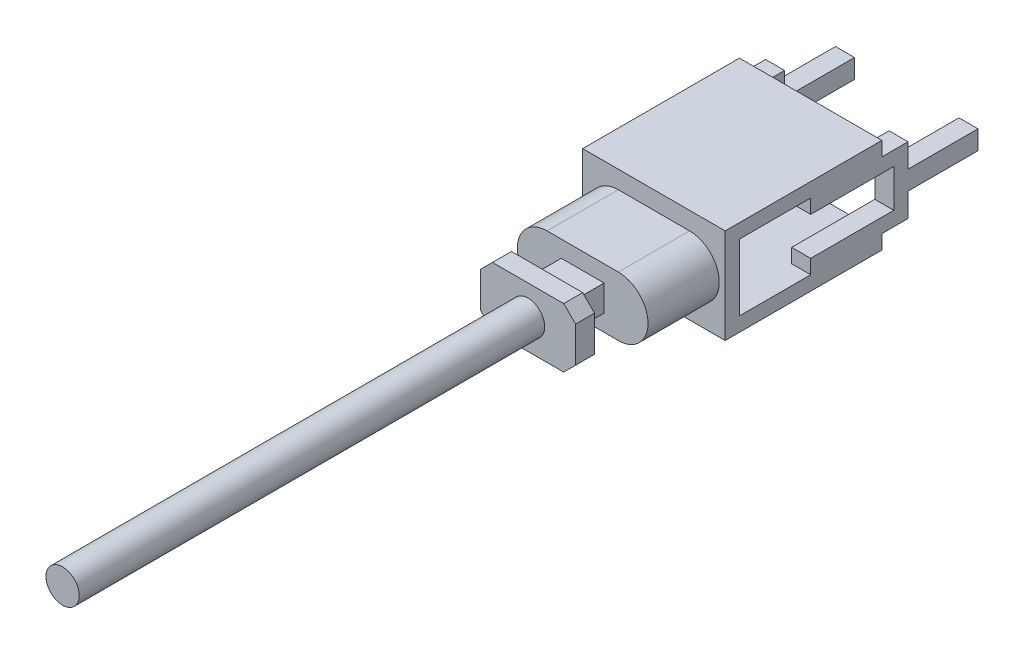
from build123d import *

# Parameters (mm, degrees)
SKETCH_1_R             = 7
EXTRUDE_1_DEPTH        = 160
EXTRUDE_1_DEPTH_BACK   = 36
SKETCH_2_R             = 7
EXTRUDE_2_DEPTH        = 8
SKETCH_3_W             = 18
SKETCH_3_H             = 11
EXTRUDE_3_DEPTH        = 15
EXTRUDE_4_DEPTH        = 30
SKETCH_5_W             = 60
SKETCH_5_H             = 40
EXTRUDE_5_DEPTH        = 6
SKETCH_6_W             = 60
SKETCH_6_H             = 6
EXTRUDE_6_DEPTH        = 60
SKETCH_7_W             = 29.455878384
SKETCH_7_H             = 4
EXTRUDE_7_DEPTH        = 8
PATTERN_LINEAR_1_COUNT = 2
PATTERN_LINEAR_1_PITCH = 52


with BuildPart() as part:
    # 草图1 → 凸台-拉伸1 (new body, two sides)
    with BuildSketch(Plane.XY) as extrude_1_sk:
        Circle(SKETCH_1_R)
    extrude(amount=EXTRUDE_1_DEPTH)
    extrude(extrude_1_sk.sketch, amount=-EXTRUDE_1_DEPTH_BACK)

    # 草图2 → 凸台-拉伸2 (add)
    with BuildSketch(Plane(origin=(0, 0, -36), x_dir=(-1, 0, 0), z_dir=(0, 0, -1))):
        Polygon((20, 7.5), (15, 12.5), (-15, 12.5), (-20, 7.5), (-20, -7.5), (-15, -12.5), (15, -12.5), (20, -7.5), align=None)
        Circle(SKETCH_2_R, mode=Mode.SUBTRACT)
        Circle(SKETCH_2_R)
    extrude(amount=EXTRUDE_2_DEPTH)

    # 草图3 → 凸台-拉伸3 (add)
    with BuildSketch(Plane(origin=(0, 0, -44), x_dir=(-1, 0, 0), z_dir=(0, 0, -1))):
        Rectangle(SKETCH_3_W, SKETCH_3_H)
    extrude(amount=EXTRUDE_3_DEPTH)

    # 草图4 → 凸台-拉伸4 (add)
    with BuildSketch(Plane(origin=(0, 0, -59), x_dir=(-1, 0, 0), z_dir=(0, 0, -1))):
        with BuildLine():
            Line((-15, -12.5), (-15, 12.5))
            ThreePointArc((-15, 12.5), (-27.5, 0), (-15, -12.5))
        make_face()
        with BuildLine():
            ThreePointArc((-3.77502784, 5.5), (-8.385621722, 10.606601718), (-15, 12.5))
            Line((-15, 12.5), (-15, -12.5))
            ThreePointArc((-15, -12.5), (-8.385621722, -10.606601718), (-3.77502784, -5.5))
            Line((-3.77502784, -5.5), (-9, -5.5))
            Line((-9, -5.5), (-9, 5.5))
            Line((-9, 5.5), (-3.77502784, 5.5))
        make_face()
        with BuildLine():
            ThreePointArc((-2.5, 0), (-2.822928267, 2.822928267), (-3.77502784, 5.5))
            Line((-3.77502784, 5.5), (-9, 5.5))
            Line((-9, 5.5), (-9, -5.5))
            Line((-9, -5.5), (-3.77502784, -5.5))
            ThreePointArc((-3.77502784, -5.5), (-2.822928267, -2.822928267), (-2.5, 0))
        make_face()
        with BuildLine():
            ThreePointArc((3.77502784, -5.5), (2.5, 0), (3.77502784, 5.5))
            Line((3.77502784, 5.5), (-3.77502784, 5.5))
            ThreePointArc((-3.77502784, 5.5), (-2.822928267, 2.822928267), (-2.5, 0))
            ThreePointArc((-2.5, 0), (-2.822928267, -2.822928267), (-3.77502784, -5.5))
            Line((-3.77502784, -5.5), (3.77502784, -5.5))
        make_face()
        with BuildLine():
            Line((9, 5.5), (3.77502784, 5.5))
            ThreePointArc((3.77502784, 5.5), (2.5, 0), (3.77502784, -5.5))
            Line((3.77502784, -5.5), (9, -5.5))
            Line((9, -5.5), (9, 5.5))
        make_face()
        with BuildLine():
            Line((15, -12.5), (15, 12.5))
            ThreePointArc((15, 12.5), (8.385621722, 10.606601718), (3.77502784, 5.5))
            Line((3.77502784, 5.5), (9, 5.5))
            Line((9, 5.5), (9, -5.5))
            Line((9, -5.5), (3.77502784, -5.5))
            ThreePointArc((3.77502784, -5.5), (8.385621722, -10.606601718), (15, -12.5))
        make_face()
        with BuildLine():
            ThreePointArc((27.5, 0), (23.838834765, 8.838834765), (15, 12.5))
            Line((15, 12.5), (15, -12.5))
            ThreePointArc((15, -12.5), (23.838834765, -8.838834765), (27.5, 0))
        make_face()
        with BuildLine():
            Line((-15, -12.5), (15, -12.5))
            ThreePointArc((15, -12.5), (8.385621722, -10.606601718), (3.77502784, -5.5))
            Line((3.77502784, -5.5), (-3.77502784, -5.5))
            ThreePointArc((-3.77502784, -5.5), (-8.385621722, -10.606601718), (-15, -12.5))
        make_face()
        with BuildLine():
            ThreePointArc((3.77502784, 5.5), (8.385621722, 10.606601718), (15, 12.5))
            Line((15, 12.5), (-15, 12.5))
            ThreePointArc((-15, 12.5), (-8.385621722, 10.606601718), (-3.77502784, 5.5))
            Line((-3.77502784, 5.5), (3.77502784, 5.5))
        make_face()
    extrude(amount=EXTRUDE_4_DEPTH)

    # 草图5 → 凸台-拉伸5 (add)
    with BuildSketch(Plane(origin=(0, 0, -89), x_dir=(-1, 0, 0), z_dir=(0, 0, -1))):
        Rectangle(SKETCH_5_W, SKETCH_5_H)
    extrude(amount=EXTRUDE_5_DEPTH)

    # 草图6 → 凸台-拉伸6 (add)
    with BuildSketch(Plane(origin=(0, 0, -95), x_dir=(-1, 0, 0), z_dir=(0, 0, -1))):
        with Locations((0, 17)):
            Rectangle(SKETCH_6_W, SKETCH_6_H)
        with Locations((0, -17)):
            Rectangle(SKETCH_6_W, SKETCH_6_H)
    extrude(amount=EXTRUDE_6_DEPTH)

    # 草图7 → 凸台-拉伸7 (add)
    with BuildSketch(Plane.ZY.offset(30)):
        Polygon((-125, 8), (-125, 14), (-155, 14), (-160, 14), (-160, 8), align=None)
        Polygon((-125, -8), (-160, -8), (-160, -14), (-155, -14), (-125, -14), align=None)
        Polygon((-160, 8), (-160, 14), (-166, 14), (-166, 4), (-166, 0), (-166, -4), (-166, -14), (-160, -14), (-160, -8), align=None)
        with Locations((-180.727939192, -2)):
            Rectangle(SKETCH_7_W, SKETCH_7_H)
        with Locations((-180.727939192, 2)):
            Rectangle(SKETCH_7_W, SKETCH_7_H)
    extrude_7 = extrude(amount=-EXTRUDE_7_DEPTH)

    # 阵列(线性)1: 凸台-拉伸7 ×2
    with Locations(*[(i * PATTERN_LINEAR_1_PITCH, 0, 0) for i in range(1, PATTERN_LINEAR_1_COUNT)]):
        add(extrude_7)


solid = part.part
